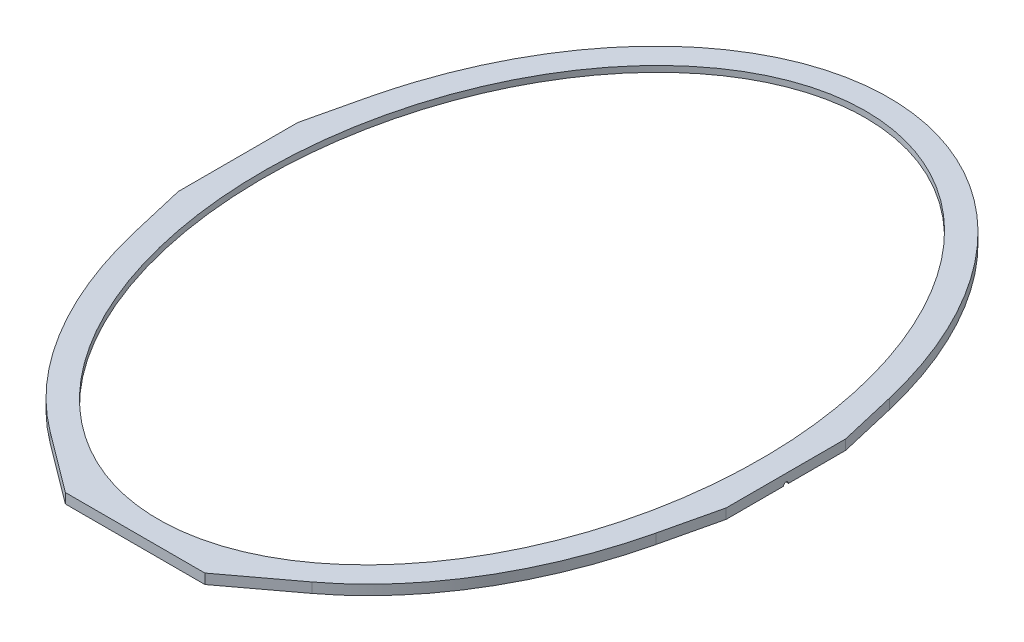
from build123d import *

# Parameters (mm, degrees)
SKETCH1_RX          = 355
SKETCH1_RY          = 250
BOSS_EXTRUDE1_DEPTH = 10
SKETCH2_RX          = 365
SKETCH2_RY          = 260
SKETCH2_RX_2        = 355
SKETCH2_RY_2        = 250
CUT_EXTRUDE1_DEPTH  = 4
BOSS_EXTRUDE2_DEPTH = 10
CUT_EXTRUDE4_DEPTH  = 10
CUT_EXTRUDE5_DEPTH  = 10


with BuildPart() as part:
    # Sketch1 → Boss-Extrude1 (new body)
    with BuildSketch(Plane(origin=(0, 0, 0), x_dir=(1, 0, 0), z_dir=(0, 1, 0))):
        with BuildLine():
            Line((-275, 60), (-275, -60))
            Line((-275, -60), (-261.621622, -117.081081))
            add(Edge.make_bspline(
                [(-261.621622, -117.081081), (0, -1222.344863), (261.621622, -117.081081)],
                knots=[5.027046, 5.027046, 5.027046, 7.539325, 7.539325, 7.539325], degree=2, weights=[1, 0.30949, 1]))
            Line((261.621622, -117.081081), (275, -60))
            Line((275, -60), (275, 60))
            Line((275, 60), (261.621622, 117.081081))
            add(Edge.make_bspline(
                [(261.621622, 117.081081), (0, 1222.344863), (-261.621622, 117.081081)],
                knots=[5.027046, 5.027046, 5.027046, 7.539325, 7.539325, 7.539325], degree=2, weights=[1, 0.30949, 1]))
            Line((-261.621622, 117.081081), (-275, 60))
        make_face()
        with Locations(Location((0, 0), (0, 0, 90))):
            Ellipse(SKETCH1_RX, SKETCH1_RY, mode=Mode.SUBTRACT)
    extrude(amount=BOSS_EXTRUDE1_DEPTH)

    # Sketch2 → Cut-Extrude1 (cut)
    with BuildSketch(Plane.XZ):
        with Locations(Location((0, 0), (0, 0, 90))):
            Ellipse(SKETCH2_RX, SKETCH2_RY)
        with Locations(Location((0, 0), (0, 0, 90))):
            Ellipse(SKETCH2_RX_2, SKETCH2_RY_2, mode=Mode.SUBTRACT)
    extrude(amount=-CUT_EXTRUDE1_DEPTH, mode=Mode.SUBTRACT)

    # Sketch3 → Boss-Extrude2 (add)
    with BuildSketch(Plane(origin=(0, 10, 0), x_dir=(1, 0, 0), z_dir=(0, 1, 0))):
        Polygon((70, -378.303394), (-70, -378.303394), (-131.488451, -332.304138), (0, -361.875658), (131.488451, -332.304138), align=None)
    extrude(amount=-BOSS_EXTRUDE2_DEPTH)

    # Sketch4 → Cut-Extrude4 (cut)
    with BuildSketch(Plane.ZY.offset(275)):
        with BuildLine():
            Line((-2.5, 0), (2.5, 0))
            ThreePointArc((2.5, 0), (0, 2.5), (-2.5, 0))
        make_face()
    extrude(amount=-CUT_EXTRUDE4_DEPTH, mode=Mode.SUBTRACT)

    # Sketch5 → Cut-Extrude5 (cut)
    with BuildSketch(Plane(origin=(275, 0, 0), x_dir=(0, 0, -1), z_dir=(1, 0, 0))):
        with BuildLine():
            Line((-2.5, 0), (2.5, 0))
            ThreePointArc((2.5, 0), (0, 2.5), (-2.5, 0))
        make_face()
    extrude(amount=-CUT_EXTRUDE5_DEPTH, mode=Mode.SUBTRACT)


solid = part.part
